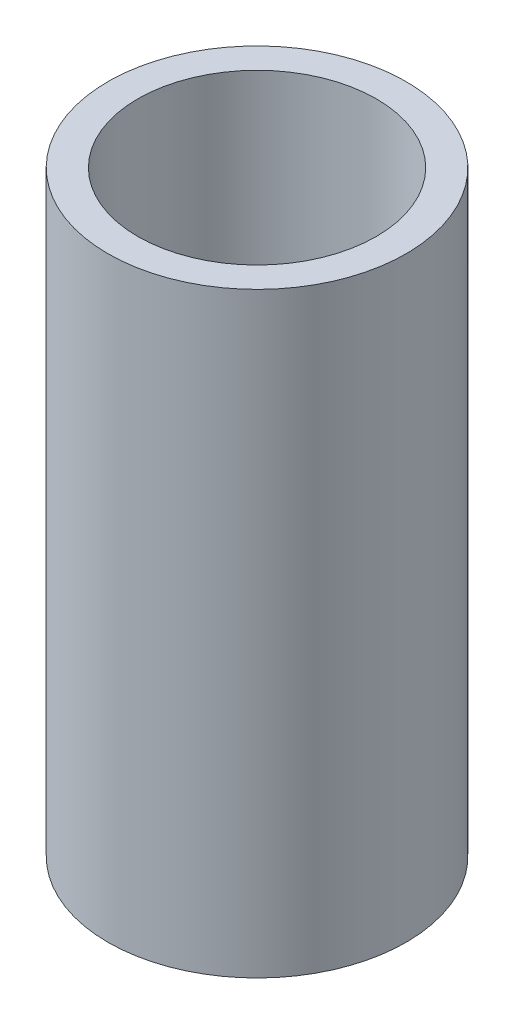
from build123d import *

# Parameters (mm, degrees)
SKETCH1_R           = 2
SKETCH1_R_2         = 1.6
BOSS_EXTRUDE1_DEPTH = 8


with BuildPart() as part:
    # Sketch1 → Boss-Extrude1 (new body)
    with BuildSketch(Plane(origin=(0, 0, 0), x_dir=(1, 0, 0), z_dir=(0, 1, 0))):
        Circle(SKETCH1_R)
        Circle(SKETCH1_R_2, mode=Mode.SUBTRACT)
    extrude(amount=BOSS_EXTRUDE1_DEPTH)


solid = part.part
